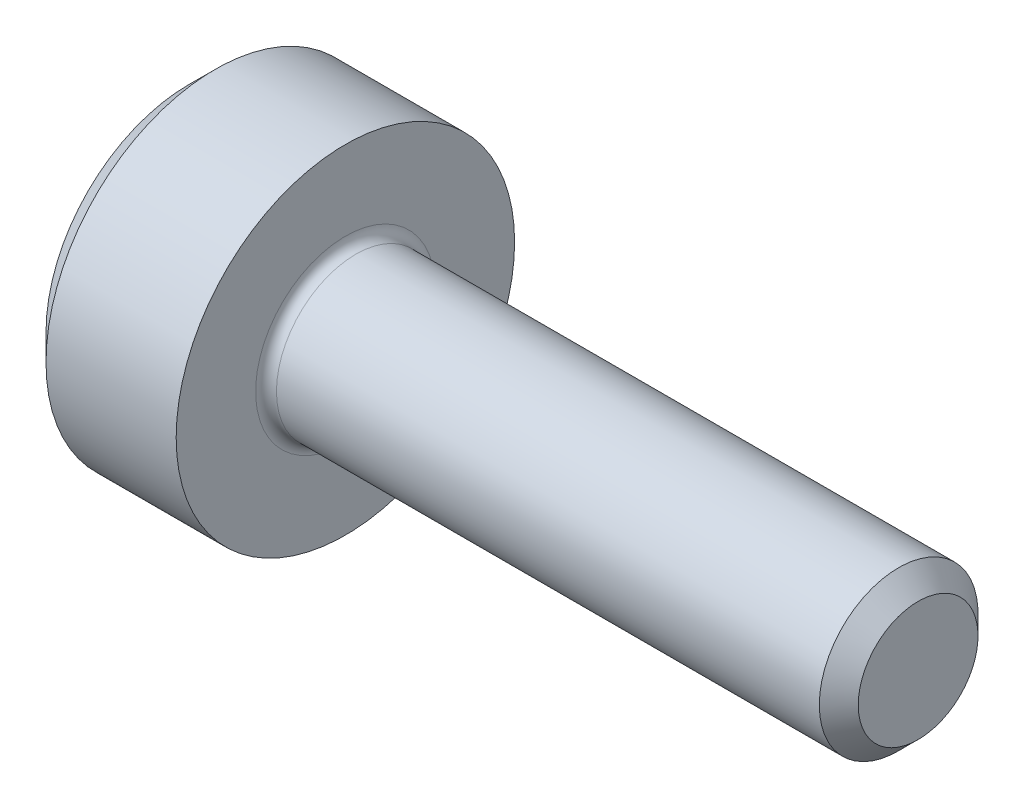
from build123d import *

# Parameters (mm, degrees)
FILLET1_R   = 0.2
HEX_2_DEPTH = 2.5


with BuildPart() as part:
    # BodySke → Base-Revolve (revolve)
    with BuildSketch(Plane.XY):
        Polygon((0, 0), (0, 2.75), (0.5, 3.25), (3, 3.25), (3, 1.524), (13.626, 1.524), (14, 1.15), (14, 0), align=None)
    revolve(axis=Axis((-31.75, 0, 0), (1, 0, 0)))

    # Fillet1
    fillet1_edges = [part.edges().sort_by_distance(p)[0] for p in [
        (3, -1.524, 0),
    ]]
    fillet(fillet1_edges, radius=FILLET1_R)

    # Sketch2 → Hex-PreBroach (revolve, cut)
    with BuildSketch(Plane.XY):
        Polygon((0, 1.6), (2.5, 1.6), (3.423760431, 0), (0, 0), align=None)
    revolve(axis=Axis((0, 0, 0), (1, 0, 0)), mode=Mode.SUBTRACT)

    # Sketch3 → Hex 2 (cut)
    with BuildSketch(Plane(origin=(0, 0, 0), x_dir=(0, 0.5, 0.866025404), z_dir=(-1, 0, 0))):
        Polygon((0.923760431, 1.6), (-0.923760431, 1.6), (-1.847520861, 0), (-0.923760431, -1.6), (0.923760431, -1.6), (1.847520861, 0), align=None)
    extrude(amount=-HEX_2_DEPTH, mode=Mode.SUBTRACT)


solid = part.part
